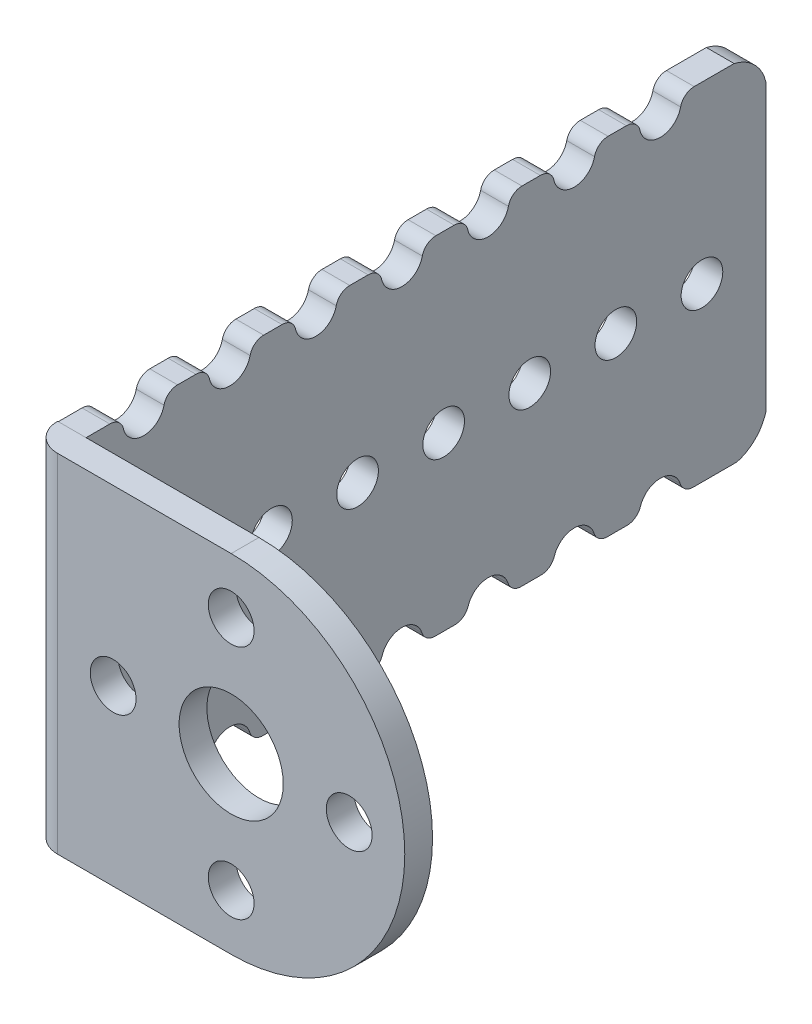
from build123d import *

# Parameters (mm, degrees)
CROQUIS1_R              = 3.75
CROQUIS1_R_2            = 1.65
SALIENTE_EXTRUIR1_DEPTH = 2
SALIENTE_EXTRUIR2_DEPTH = 2
CROQUIS5_R              = 1.5
CORTAR_EXTRUIR2_DEPTH   = 10
REDONDEO3_R             = 1
REDONDEO4_R             = 1
REDONDEO5_R             = 1
REDONDEO6_R             = 1
REDONDEO7_R             = 1
REDONDEO8_R             = 1
REDONDEO12_R            = 2


with BuildPart() as part:
    # Croquis1 → Saliente-Extruir1 (new body)
    with BuildSketch(Plane.XY):
        with BuildLine():
            Line((0, 0), (0, 25))
            Line((0, 25), (14.5, 25))
            ThreePointArc((14.5, 25), (27, 12.5), (14.5, 0))
            Line((14.5, 0), (0, 0))
        make_face()
        with Locations((14.5, 12.5)):
            Circle(CROQUIS1_R, mode=Mode.SUBTRACT)
        with Locations((14.5, 21)):
            Circle(CROQUIS1_R_2, mode=Mode.SUBTRACT)
        with Locations((23, 12.5)):
            Circle(CROQUIS1_R_2, mode=Mode.SUBTRACT)
        with Locations((14.5, 4)):
            Circle(CROQUIS1_R_2, mode=Mode.SUBTRACT)
        with Locations((6, 12.5)):
            Circle(CROQUIS1_R_2, mode=Mode.SUBTRACT)
    extrude(amount=SALIENTE_EXTRUIR1_DEPTH)

    # Croquis4 → Saliente-Extruir2 (add)
    with BuildSketch(Plane.ZY):
        with BuildLine():
            Line((2, 0), (-46.922808665, 0))
            ThreePointArc((-46.922808665, 0), (-48.234090069, 0.765909931), (-49, 2.077191335))
            Line((-49, 2.077191335), (-49, 22.665501207))
            ThreePointArc((-49, 22.665501207), (-48.183232344, 24.133251816), (-46.715481735, 24.950019472))
            Line((-46.715481735, 24.950019472), (2, 24.950019472))
            Line((2, 24.950019472), (2, 0))
        make_face()
    extrude(amount=-SALIENTE_EXTRUIR2_DEPTH)

    # Croquis5 → Cortar-Extruir2 (cut)
    with BuildSketch(Plane(origin=(2, 0, 0), x_dir=(0, 0, -1), z_dir=(1, 0, 0))):
        with Locations((44.4, 12.371346271)):
            Circle(CROQUIS5_R)
        with Locations((38.2, 12.371346271)):
            Circle(CROQUIS5_R)
        with Locations((32, 12.371346271)):
            Circle(CROQUIS5_R)
        with Locations((25.8, 12.371346271)):
            Circle(CROQUIS5_R)
        with Locations((19.6, 12.371346271)):
            Circle(CROQUIS5_R)
        with Locations((13.4, 12.371346271)):
            Circle(CROQUIS5_R)
        with Locations((7.2, 12.371346271)):
            Circle(CROQUIS5_R)
        with Locations((4.2, 24.5)):
            Circle(CROQUIS5_R)
        with Locations((10.4, 24.5)):
            Circle(CROQUIS5_R)
        with Locations((16.6, 24.5)):
            Circle(CROQUIS5_R)
        with Locations((22.8, 24.5)):
            Circle(CROQUIS5_R)
        with Locations((29, 24.5)):
            Circle(CROQUIS5_R)
        with Locations((35.2, 24.5)):
            Circle(CROQUIS5_R)
        with Locations((41.4, 24.5)):
            Circle(CROQUIS5_R)
        with Locations((41.4, 0.242692542)):
            Circle(CROQUIS5_R)
        with Locations((35.2, 0.242692542)):
            Circle(CROQUIS5_R)
        with Locations((29, 0.242692542)):
            Circle(CROQUIS5_R)
        with Locations((22.8, 0.242692542)):
            Circle(CROQUIS5_R)
        with Locations((16.6, 0.242692542)):
            Circle(CROQUIS5_R)
        with Locations((10.4, 0.242692542)):
            Circle(CROQUIS5_R)
        with Locations((4.2, 0.242692542)):
            Circle(CROQUIS5_R)
    extrude(amount=-CORTAR_EXTRUIR2_DEPTH, mode=Mode.SUBTRACT)

    # Redondeo3
    redondeo3_edges = [part.edges().sort_by_distance(p)[0] for p in [
        (1, 24.950019472, -5.630902678),
        (1, 24.950019472, -8.969097322),
    ]]
    fillet(redondeo3_edges, radius=REDONDEO3_R)

    # Redondeo4
    redondeo4_edges = [part.edges().sort_by_distance(p)[0] for p in [
        (1, 24.950019472, -21.369097322),
        (1, 24.950019472, -11.830902678),
        (1, 24.950019472, -15.169097322),
        (1, 24.950019472, -18.030902678),
    ]]
    fillet(redondeo4_edges, radius=REDONDEO4_R)

    # Redondeo5
    redondeo5_edges = [part.edges().sort_by_distance(p)[0] for p in [
        (1, 24.950019472, -39.969097322),
        (1, 24.950019472, -42.830902678),
        (1, 24.950019472, -33.769097322),
        (1, 24.950019472, -36.630902678),
        (1, 24.950019472, -27.569097322),
        (1, 24.950019472, -30.430902678),
        (1, 24.950019472, -24.230902678),
    ]]
    fillet(redondeo5_edges, radius=REDONDEO5_R)

    # Redondeo6
    redondeo6_edges = [part.edges().sort_by_distance(p)[0] for p in [
        (1, 24.950019472, -2.769097322),
    ]]
    fillet(redondeo6_edges, radius=REDONDEO6_R)

    # Redondeo7
    redondeo7_edges = [part.edges().sort_by_distance(p)[0] for p in [
        (1, 0, -27.519763421),
        (1, 0, -21.319763421),
        (1, 0, -24.280236579),
        (1, 0, -15.119763421),
        (1, 0, -18.080236579),
        (1, 0, -8.919763421),
        (1, 0, -11.880236579),
        (1, 0, -2.719763421),
        (1, 0, -5.680236579),
    ]]
    fillet(redondeo7_edges, radius=REDONDEO7_R)

    # Redondeo8
    redondeo8_edges = [part.edges().sort_by_distance(p)[0] for p in [
        (1, 0, -33.719763421),
        (1, 0, -36.680236579),
        (1, 0, -39.919763421),
        (1, 0, -42.880236579),
        (1, 0, -30.480236579),
    ]]
    fillet(redondeo8_edges, radius=REDONDEO8_R)

    # Redondeo12
    redondeo12_edges = [part.edges().sort_by_distance(p)[0] for p in [
        (0, 12.5, 2),
    ]]
    fillet(redondeo12_edges, radius=REDONDEO12_R)


solid = part.part
